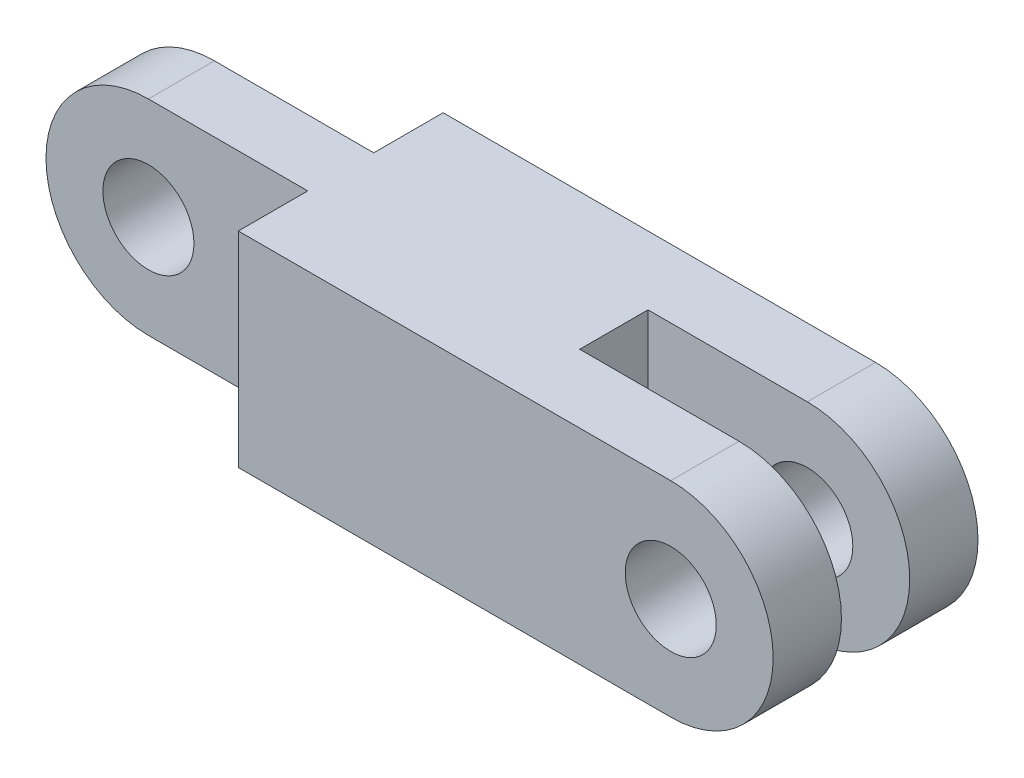
from build123d import *

# Parameters (mm, degrees)
BOSS_EXTRUDE1_DEPTH      = 7.25
BOSS_EXTRUDE1_DEPTH_BACK = 7.25
SKETCH1_R                = 10
SKETCH2_W                = 45
SKETCH2_H                = 45
BOSS_EXTRUDE2_DEPTH      = 60
SKETCH3_R                = 10
BOSS_EXTRUDE3_DEPTH      = 15


with BuildPart() as part:
    # Sketch1 → Boss-Extrude1 (new, two sides: drawn at the far end of the back side and taken through both)
    with BuildSketch(Plane.XY.offset(-BOSS_EXTRUDE1_DEPTH_BACK)):
        with BuildLine():
            Line((0, 22.5), (0, -22.5))
            Line((0, -22.5), (-35, -22.5))
            ThreePointArc((-35, -22.5), (-57.5, 0), (-35, 22.5))
            Line((-35, 22.5), (0, 22.5))
        make_face()
        with Locations((-35, 0)):
            Circle(SKETCH1_R, mode=Mode.SUBTRACT)
    extrude(amount=BOSS_EXTRUDE1_DEPTH + BOSS_EXTRUDE1_DEPTH_BACK)

    # Sketch2 → Boss-Extrude2 (add)
    with BuildSketch(Plane(origin=(0, 0, 0), x_dir=(0, 0, -1), z_dir=(1, 0, 0))):
        Rectangle(SKETCH2_W, SKETCH2_H)
    extrude(amount=BOSS_EXTRUDE2_DEPTH)

    # Sketch3 → Boss-Extrude3 (add)
    with BuildSketch(Plane.XY.offset(7.5)):
        with BuildLine():
            Line((60, 22.5), (60, -22.5))
            Line((60, -22.5), (95, -22.5))
            ThreePointArc((95, -22.5), (117.5, 0), (95, 22.5))
            Line((95, 22.5), (60, 22.5))
        make_face()
        with Locations((95, 0)):
            Circle(SKETCH3_R, mode=Mode.SUBTRACT)
    boss_extrude3 = extrude(amount=BOSS_EXTRUDE3_DEPTH)

    # Mirror1: Boss-Extrude3 across plane
    add(boss_extrude3.mirror(Plane.XY))


solid = part.part
